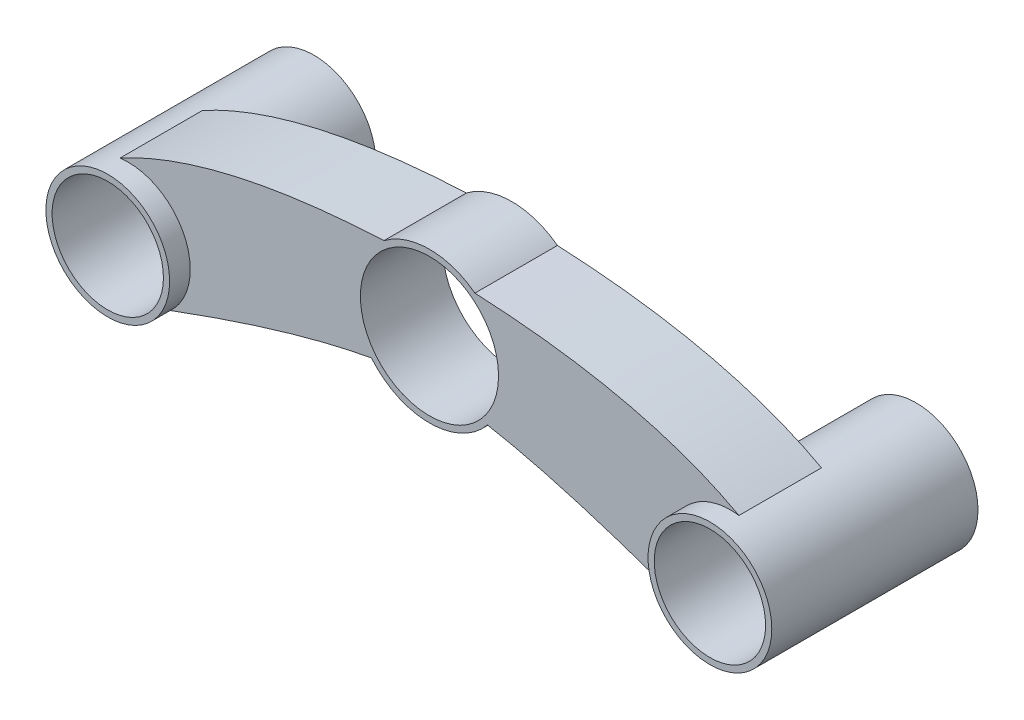
from build123d import *

# Parameters (mm, degrees)
SKETCH1_R             = 15
SKETCH1_R_2           = 13.5
BOSS_EXTRUDE1_DEPTH   = 50
BOSS_EXTRUDE1_2_DEPTH = 50
SKETCH2_R             = 16.75
BOSS_EXTRUDE5_DEPTH   = 20


with BuildPart() as part:
    # Sketch1 → Boss-Extrude1 (new body)
    with BuildSketch(Plane.XY):
        Circle(SKETCH1_R)
        Circle(SKETCH1_R_2, mode=Mode.SUBTRACT)
    extrude(amount=BOSS_EXTRUDE1_DEPTH)


with BuildPart() as body_2:
    # Sketch1 → Boss-Extrude1 2 (new body)
    with BuildSketch(Plane.XY):
        with Locations((146, 0)):
            Circle(SKETCH1_R)
        with Locations((146, 0)):
            Circle(SKETCH1_R_2, mode=Mode.SUBTRACT)
    extrude(amount=BOSS_EXTRUDE1_2_DEPTH)


with BuildPart() as body_3:
    # Sketch2 → Boss-Extrude5 (new body)
    with BuildSketch(Plane.XY.offset(25)):
        with BuildLine():
            ThreePointArc((58.930048431, 3.376792059), (73, -3.25), (87.069951569, 3.376792059))
            add(Edge.make_bspline(
                [(135.858074214, -11.051757388), (106.393657142, -0.108887447), (87.069951569, 3.376792059)],
                knots=[0, 0, 0, 1, 1, 1], degree=2))
            ThreePointArc((135.858074214, -11.051757388), (132.425663063, 6.382583858), (148.04182941, 14.860381309))
            add(Edge.make_bspline(
                [(148.04182941, 14.860381309), (124.723417301, 27.619088806), (84.024892619, 29.54352924)],
                knots=[0, 0, 0, 1, 1, 1], degree=2))
            ThreePointArc((84.024892619, 29.54352924), (73, 33.25), (61.975107381, 29.54352924))
            add(Edge.make_bspline(
                [(-2.04182941, 14.860381309), (21.276582699, 27.619088806), (61.975107381, 29.54352924)],
                knots=[0, 0, 0, 1, 1, 1], degree=2))
            ThreePointArc((-2.04182941, 14.860381309), (13.574336937, 6.382583858), (10.141925786, -11.051757388))
            add(Edge.make_bspline(
                [(10.141925786, -11.051757388), (39.606342858, -0.108887447), (58.930048431, 3.376792059)],
                knots=[0, 0, 0, 1, 1, 1], degree=2))
        make_face()
        with Locations((73, 15)):
            Circle(SKETCH2_R, mode=Mode.SUBTRACT)
    extrude(amount=BOSS_EXTRUDE5_DEPTH)


solid = Compound([part.part, body_2.part, body_3.part])
